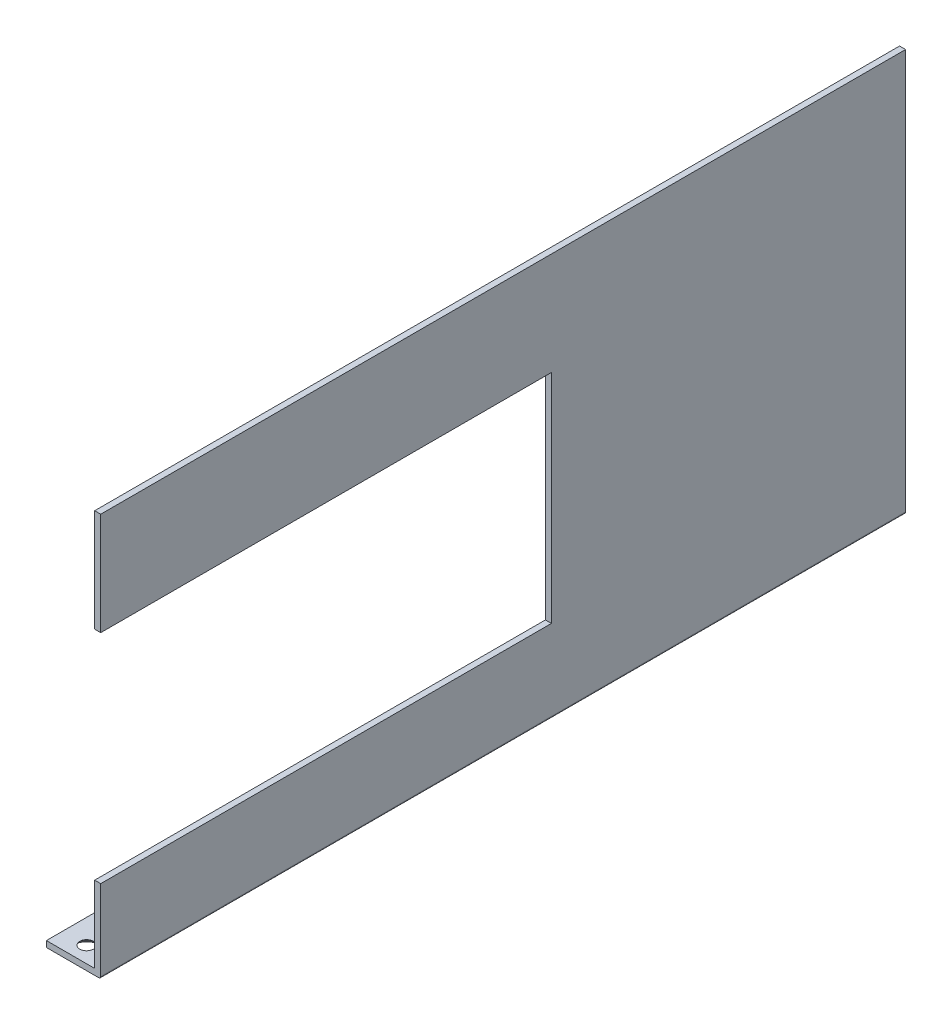
from build123d import *

# Parameters (mm, degrees)
EXTRUDE1_DEPTH                               = 200
FILLET1_R                                    = 0.5
CUT_EXTRUDE2_START                           = 200
SKETCH2_W                                    = 1.5
SKETCH2_H                                    = 54
CUT_EXTRUDE2_DEPTH                           = 112
CSK_FOR_M3_COUNTERSUNK_FLAT_HEAD_SCR_2_COUNT = 2
CSK_FOR_M3_COUNTERSUNK_FLAT_HEAD_SCR_2_PITCH = 192


with BuildPart() as part:
    # Sketch1 → Extrude1 (new body)
    with BuildSketch(Plane.XY):
        Polygon((0, 0), (13.5, 0), (13.5, 100), (12, 100), (12, 1.5), (0, 1.5), align=None)
    extrude(amount=EXTRUDE1_DEPTH)

    # Fillet1
    fillet1_edges = [part.edges().sort_by_distance(p)[0] for p in [
        (13.5, 0, 100),
    ]]
    fillet(fillet1_edges, radius=FILLET1_R)

    # Sketch2 → Cut-Extrude2 (cut)
    with BuildSketch(Plane.XY.offset(CUT_EXTRUDE2_START)):
        with Locations((12.75, 47.5)):
            Rectangle(SKETCH2_W, SKETCH2_H)
    extrude(amount=-CUT_EXTRUDE2_DEPTH, mode=Mode.SUBTRACT)

    # Sketch5 → CSK for M3 Countersunk Flat Head Screw1 (revolve, cut)
    with BuildSketch(Plane(origin=(6, 0, 196), x_dir=(0, 0, -1), z_dir=(1, 0, 0))):
        Polygon((0, 0), (0, 2.521463052), (1.7, 1.5), (1.7, 1.45), (3.15, 0), align=None)
    csk_for_m3_countersunk_flat_head_screw1 = revolve(axis=Axis((6, -6.35, 196), (0, 1, 0)), mode=Mode.SUBTRACT)

    # CSK for M3 Countersunk Flat Head Scr 2: CSK for M3 Countersunk Flat Head Screw1 ×2
    with Locations(*[(0, 0, -i * CSK_FOR_M3_COUNTERSUNK_FLAT_HEAD_SCR_2_PITCH) for i in range(1, CSK_FOR_M3_COUNTERSUNK_FLAT_HEAD_SCR_2_COUNT)]):
        add(csk_for_m3_countersunk_flat_head_screw1, mode=Mode.SUBTRACT)


solid = part.part
